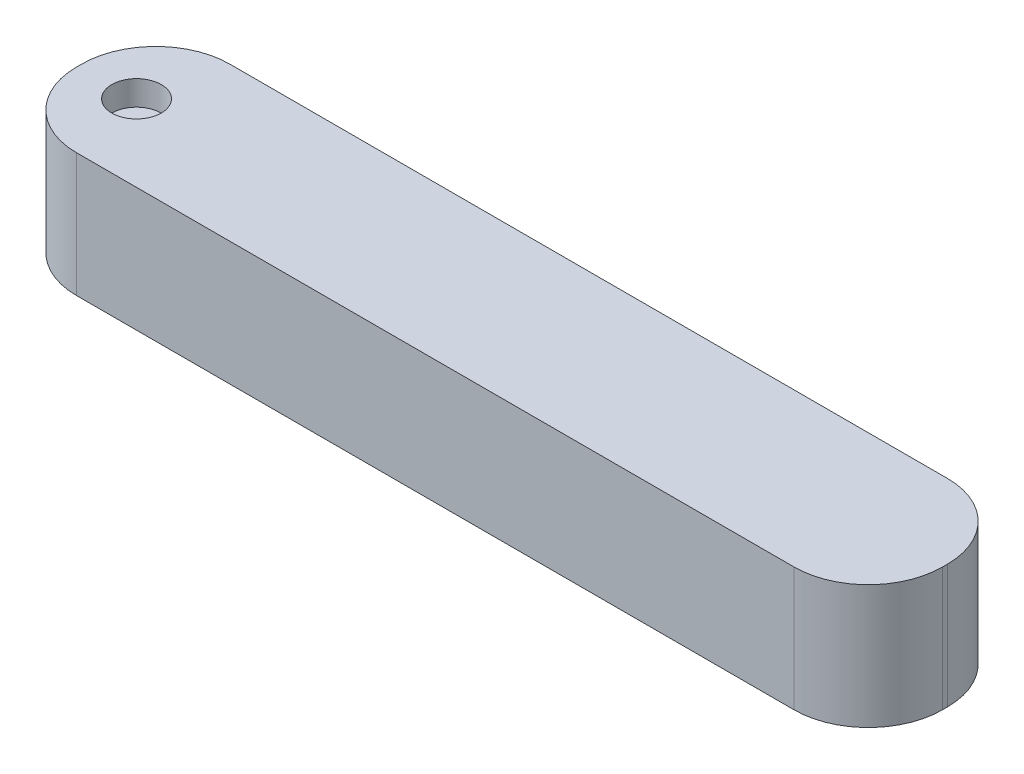
from build123d import *

# Parameters (mm, degrees)
SKETCH1_W           = 88.9
SKETCH1_H           = 15.748
BOSS_EXTRUDE1_DEPTH = 12.7
FILLET1_R           = 7.62
SKETCH2_R           = 2.54
CUT_EXTRUDE1_DEPTH  = 2.54
SKETCH3_R           = 2.54
CUT_EXTRUDE2_DEPTH  = 7.62
SKETCH4_R           = 1.016
CUT_EXTRUDE3_DEPTH  = 5.08


with BuildPart() as part:
    # Sketch1 → Boss-Extrude1 (new body)
    with BuildSketch(Plane(origin=(0, 0, 0), x_dir=(1, 0, 0), z_dir=(0, 1, 0))):
        with Locations((12.118156109, 3.2385)):
            Rectangle(SKETCH1_W, SKETCH1_H)
    extrude(amount=BOSS_EXTRUDE1_DEPTH)

    # Fillet1
    fillet1_edges = [part.edges().sort_by_distance(p)[0] for p in [
        (-32.331843891, 6.35, -11.1125),
        (56.568156109, 6.35, -11.1125),
        (56.568156109, 6.35, 4.6355),
        (-32.331843891, 6.35, 4.6355),
    ]]
    fillet(fillet1_edges, radius=FILLET1_R)

    # Sketch2 → Cut-Extrude1 (cut)
    with BuildSketch(Plane(origin=(0, 12.7, 0), x_dir=(1, 0, 0), z_dir=(0, 1, 0))):
        with Locations((-26.428712343, 3.2385)):
            Circle(SKETCH2_R)
    extrude(amount=-CUT_EXTRUDE1_DEPTH, mode=Mode.SUBTRACT)

    # Sketch3 → Cut-Extrude2 (cut)
    with BuildSketch(Plane.XZ):
        with Locations((-26.428712343, -3.2385)):
            Circle(SKETCH3_R)
    extrude(amount=-CUT_EXTRUDE2_DEPTH, mode=Mode.SUBTRACT)

    # Sketch4 → Cut-Extrude3 (cut)
    with BuildSketch(Plane(origin=(0, 10.16, 0), x_dir=(1, 0, 0), z_dir=(0, 1, 0))):
        with Locations((-26.428712343, 3.2385)):
            Circle(SKETCH4_R)
    extrude(amount=-CUT_EXTRUDE3_DEPTH, mode=Mode.SUBTRACT)


solid = part.part
